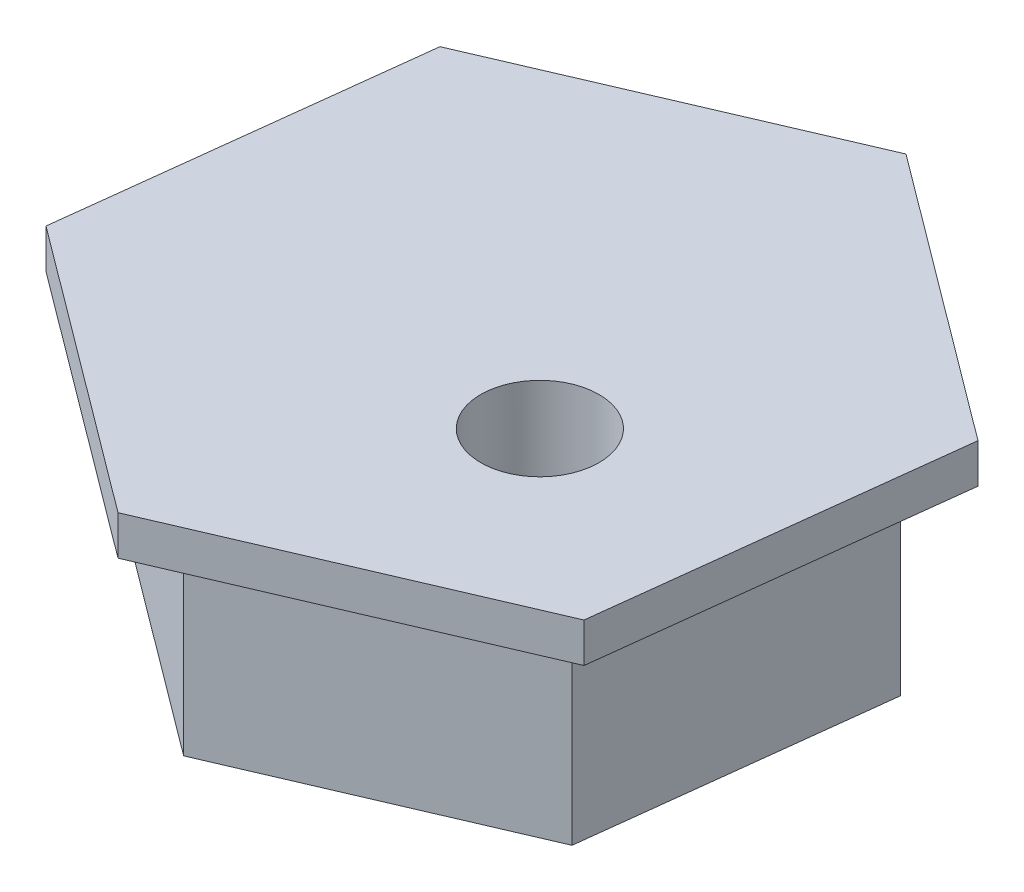
from build123d import *

# Parameters (mm, degrees)
SKETCH1_R           = 1.5
BOSS_EXTRUDE1_DEPTH = 6
BOSS_EXTRUDE2_DEPTH = 1
SKETCH4_R           = 1.5
CUT_EXTRUDE1_DEPTH  = 1


with BuildPart() as part:
    # Sketch1 → Boss-Extrude1 (new body)
    with BuildSketch(Plane(origin=(0, 0, 0), x_dir=(1, 0, 0), z_dir=(0, 1, 0))):
        Polygon((-6.890880132, -2.960704478), (-0.881394775, -7.448029488), (6.009485357, -4.48732501), (6.890880132, 2.960704478), (0.881394775, 7.448029488), (-6.009485357, 4.48732501), align=None)
        with Locations((2.445675843, -1.738841474)):
            Circle(SKETCH1_R, mode=Mode.SUBTRACT)
    extrude(amount=BOSS_EXTRUDE1_DEPTH)

    # Sketch2 → Boss-Extrude2 (add)
    with BuildSketch(Plane(origin=(0, 6, 0), x_dir=(1, 0, 0), z_dir=(0, 1, 0))):
        Polygon((8.269056159, 3.552845373), (1.05767373, 8.937635385), (-7.211382428, 5.384790012), (-8.269056159, -3.552845373), (-1.05767373, -8.937635385), (7.211382428, -5.384790012), align=None)
    extrude(amount=-BOSS_EXTRUDE2_DEPTH)

    # Sketch4 → Cut-Extrude1 (cut)
    with BuildSketch(Plane.XZ.offset(-5)):
        with Locations((2.445675843, 1.738841474)):
            Circle(SKETCH4_R)
    extrude(amount=-CUT_EXTRUDE1_DEPTH, mode=Mode.SUBTRACT)


solid = part.part
